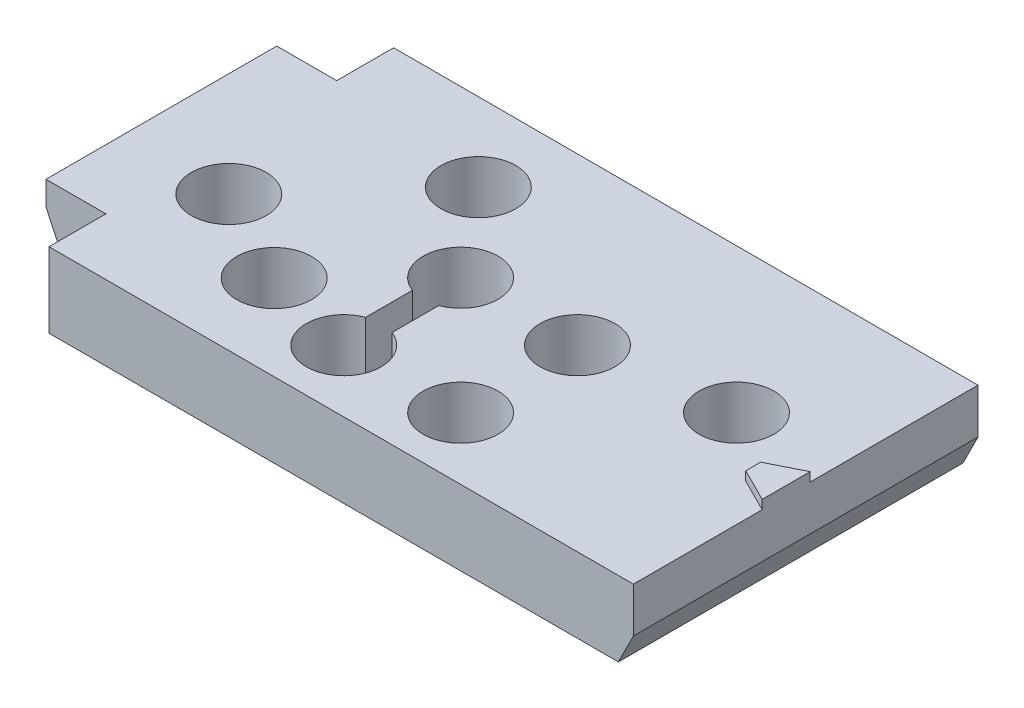
from build123d import *

# Parameters (mm, degrees)
BOSS_EXTRUDE1_DEPTH = 6.35
SKETCH2_R           = 3.175
CUT_EXTRUDE1_DEPTH  = 5.588
BOSS_EXTRUDE2_DEPTH = 0.762
SKETCH4_R           = 1.016
CUT_EXTRUDE2_DEPTH  = 7.35
CUT_EXTRUDE3_DEPTH  = 30.21
CUT_EXTRUDE4_DEPTH  = 25.384


with BuildPart() as part:
    # Sketch1 → Boss-Extrude1 (new body)
    with BuildSketch(Plane(origin=(0, 0, 0), x_dir=(1, 0, 0), z_dir=(0, 1, 0))):
        Polygon((77.849076972, 47.983166812), (28.319076972, 47.983166812), (28.319076972, 43.157166812), (23.239076972, 43.157166812), (23.239076972, 23.599166812), (28.319076972, 23.599166812), (28.319076972, 18.773166812), (77.849076972, 18.773166812), align=None)
    extrude(amount=-BOSS_EXTRUDE1_DEPTH)

    # Sketch2 → Cut-Extrude1 (cut)
    with BuildSketch(Plane(origin=(0, 0, 0), x_dir=(1, 0, 0), z_dir=(0, 1, 0))):
        with Locations((42.143084751, 41.34242402)):
            Circle(SKETCH2_R)
        with Locations((32.069218962, 30.263111699)):
            Circle(SKETCH2_R)
        with Locations((40.161790785, 26.014596512)):
            Circle(SKETCH2_R)
        with Locations((57.943162236, 33.942485163)):
            Circle(SKETCH2_R)
        with Locations((57.943162236, 24.036485163)):
            Circle(SKETCH2_R)
        with Locations((69.631305355, 35.731766034)):
            Circle(SKETCH2_R)
        with BuildLine():
            Line((46.919562236, 30.970685163), (46.919562236, 27.008285163))
            ThreePointArc((46.919562236, 27.008285163), (48.037162236, 20.861485163), (49.154762236, 27.008285163))
            Line((49.154762236, 27.008285163), (49.154762236, 30.970685163))
            ThreePointArc((49.154762236, 30.970685163), (48.037162236, 37.117485163), (46.919562236, 30.970685163))
        make_face()
    extrude(amount=-CUT_EXTRUDE1_DEPTH, mode=Mode.SUBTRACT)

    # Sketch3 → Boss-Extrude2 (add)
    with BuildSketch(Plane(origin=(0, 0, 0), x_dir=(1, 0, 0), z_dir=(0, 1, 0))):
        Polygon((77.849076972, 33.759166812), (75.055076972, 32.362166812), (75.055076972, 31.092166812), (77.849076972, 29.695166812), align=None)
    extrude(amount=BOSS_EXTRUDE2_DEPTH)

    # Sketch4 → Cut-Extrude2 (cut, through all)
    with BuildSketch(Plane(origin=(0, 0, 0), x_dir=(1, 0, 0), z_dir=(0, 1, 0))):
        with Locations((69.631305355, 35.731766034)):
            Circle(SKETCH4_R)
        with Locations((40.161790785, 26.014596512)):
            Circle(SKETCH4_R)
    extrude(amount=-CUT_EXTRUDE2_DEPTH, mode=Mode.SUBTRACT)

    # Sketch5 → Cut-Extrude3 (cut, through all)
    with BuildSketch(Plane.XY.offset(-18.773166812)):
        Polygon((77.849076972, -3.81), (76.579076972, -6.35), (77.849076972, -6.35), align=None)
    extrude(amount=-CUT_EXTRUDE3_DEPTH, mode=Mode.SUBTRACT)

    # Sketch6 → Cut-Extrude4 (cut, through all)
    with BuildSketch(Plane.XY.offset(-23.599166812)):
        Polygon((25.271076972, -6.35), (23.239076972, -2.032), (23.239076972, -6.35), align=None)
    extrude(amount=-CUT_EXTRUDE4_DEPTH, mode=Mode.SUBTRACT)


solid = part.part
